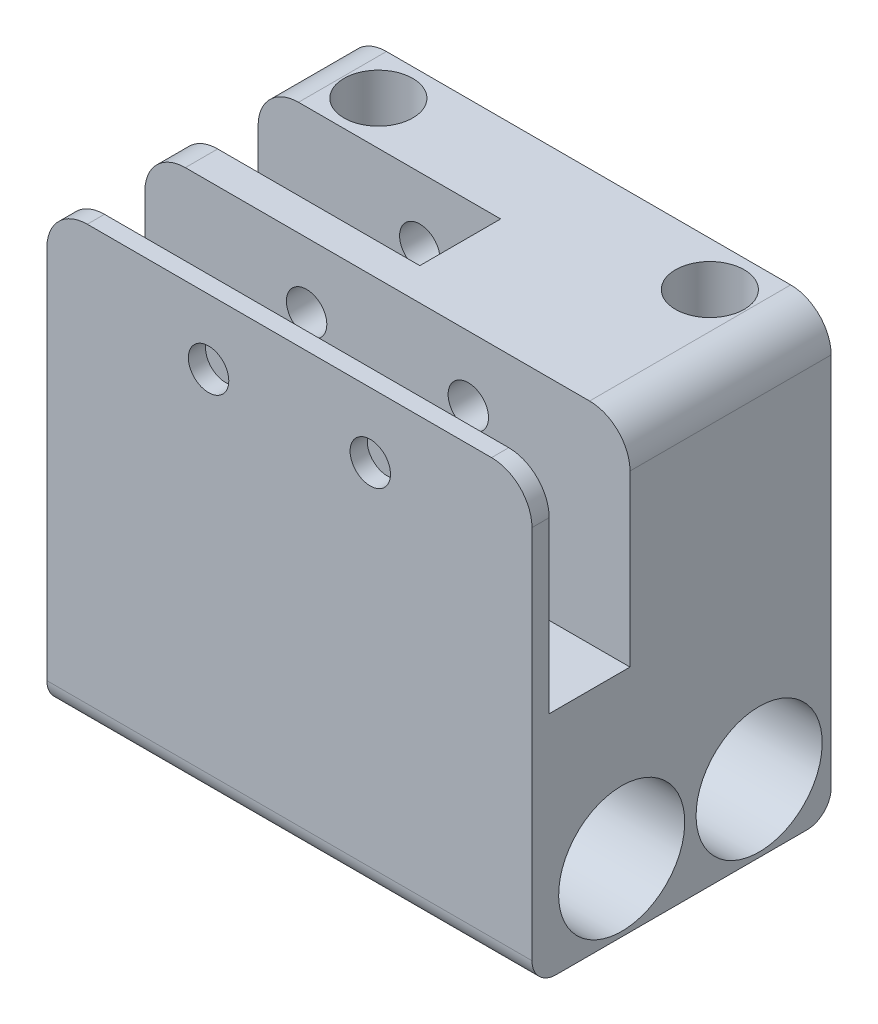
from build123d import *

# Parameters (mm, degrees)
RESSALTO_EXTRUS_O1_DEPTH = 40
ESBO_O4_R                = 7.8
CORTE_EXTRUS_O1_DEPTH    = 61
CORTE_EXTRUS_O2_DEPTH    = 3
FILETE2_R                = 3
CORTE_EXTRUS_O4_DEPTH    = 61
CORTE_EXTRUS_O5_DEPTH    = 30
ESBO_O10_R               = 2.5
CORTE_EXTRUS_O6_DEPTH    = 38
ESBO_O11_R               = 4.25
CORTE_EXTRUS_O7_DEPTH    = 30


with BuildPart() as part:
    # Esboço2 → Ressalto-extrusão1 (new body)
    with BuildSketch(Plane.XY):
        with BuildLine():
            Line((-246.218768802, 113.822486613), (-237.781231198, 113.822486613))
            Line((-237.781231198, 113.822486613), (-201.966801004, 113.822486613))
            Line((-201.966801004, 113.822486613), (-194.033198996, 113.822486613))
            Line((-194.033198996, 113.822486613), (-190, 113.822486613))
            Line((-190, 113.822486613), (-190, 138.123568891))
            Line((-190, 138.123568891), (-190, 163.212189341))
            ThreePointArc((-190, 163.212189341), (-191.464466094, 166.747723246), (-195, 168.212189341))
            Line((-195, 168.212189341), (-245, 168.212189341))
            ThreePointArc((-245, 168.212189341), (-248.535533906, 166.747723246), (-250, 163.212189341))
            Line((-250, 163.212189341), (-250, 138.123568891))
            Line((-250, 138.123568891), (-250, 113.822486613))
            Line((-250, 113.822486613), (-246.218768802, 113.822486613))
        make_face()
    extrude(amount=RESSALTO_EXTRUS_O1_DEPTH)

    # Esboço4 → Corte-extrusão1 (cut, through all)
    with BuildSketch(Plane(origin=(-190, 0, 0), x_dir=(0, 0, -1), z_dir=(1, 0, 0))):
        with Locations((-11.90241208, 122.212171493)):
            Circle(ESBO_O4_R)
        with Locations((-28.90241208, 122.212171493)):
            Circle(ESBO_O4_R)
    extrude(amount=-CORTE_EXTRUS_O1_DEPTH, mode=Mode.SUBTRACT)

    # Esboço5 → Corte-extrusão2 (cut)
    with BuildSketch(Plane(origin=(0, 0, 0), x_dir=(-1, 0, 0), z_dir=(0, 0, -1))):
        with BuildLine():
            Line((190, 163.212189341), (190, 113.822486613))
            Line((190, 113.822486613), (250, 113.822486613))
            Line((250, 113.822486613), (250, 163.212189341))
            ThreePointArc((250, 163.212189341), (248.535533906, 166.747723246), (245, 168.212189341))
            Line((245, 168.212189341), (195, 168.212189341))
            ThreePointArc((195, 168.212189341), (191.464466094, 166.747723246), (190, 163.212189341))
        make_face()
    extrude(amount=-CORTE_EXTRUS_O2_DEPTH, mode=Mode.SUBTRACT)

    # Filete2
    filete2_edges = [part.edges().sort_by_distance(p)[0] for p in [
        (-220, 113.822486613, 40),
        (-220, 113.822486613, 3),
    ]]
    fillet(filete2_edges, radius=FILETE2_R)

    # Esboço7 → Corte-extrusão4 (cut, through all)
    with BuildSketch(Plane(origin=(-190, 0, 0), x_dir=(0, 0, -1), z_dir=(1, 0, 0))):
        Polygon((-37.874860756, 142.212171493), (-37.874860756, 152.212171493), (-37.874860756, 170.639409053), (-27.874860756, 170.639409053), (-27.874860756, 152.212171493), (-27.874860756, 142.212171493), align=None)
    extrude(amount=-CORTE_EXTRUS_O4_DEPTH, mode=Mode.SUBTRACT)

    # Esboço8 → Corte-extrusão5 (cut)
    with BuildSketch(Plane.ZY.offset(250)):
        Polygon((23.874860756, 142.212171493), (23.874860756, 152.212171493), (23.874860756, 182.191519565), (13.874860756, 182.191519565), (13.874860756, 152.212171493), (13.874860756, 142.212171493), align=None)
    extrude(amount=-CORTE_EXTRUS_O5_DEPTH, mode=Mode.SUBTRACT)

    # Esboço10 → Corte-extrusão6 (cut, through all)
    with BuildSketch(Plane.XY.offset(40)):
        with Locations((-210, 160.173107934)):
            Circle(ESBO_O10_R)
        with Locations((-230, 160.173107934)):
            Circle(ESBO_O10_R)
    extrude(amount=-CORTE_EXTRUS_O6_DEPTH, mode=Mode.SUBTRACT)

    # Esboço11 → Corte-extrusão7 (cut)
    with BuildSketch(Plane(origin=(0, 168.212189341, 0), x_dir=(1, 0, 0), z_dir=(0, 1, 0))):
        with Locations((-199.5, -8.5)):
            Circle(ESBO_O11_R)
        with Locations((-240.5, -8.5)):
            Circle(ESBO_O11_R)
    extrude(amount=-CORTE_EXTRUS_O7_DEPTH, mode=Mode.SUBTRACT)


solid = part.part
